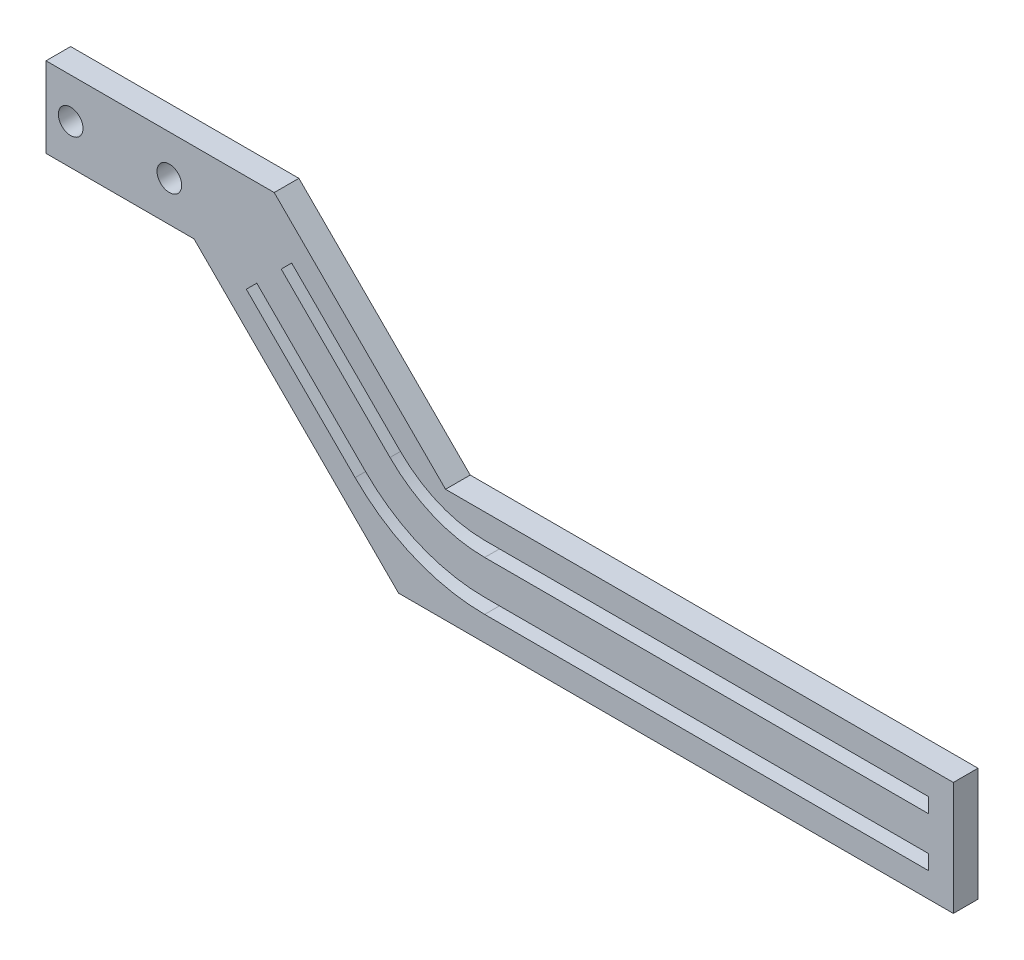
from build123d import *

# Parameters (mm, degrees)
SKETCH2_R           = 2.5
BOSS_EXTRUDE1_DEPTH = 5


with BuildPart() as part:
    # Sketch2 → Boss-Extrude1 (new body)
    with BuildSketch(Plane.XY):
        Polygon((-31.414213562, 42.727922061), (3.313708499, 8), (106.242640687, 8), (106.242640687, -15), (-6.213203436, -15), (-47.67766953, 26.464466094), (-77.67766953, 26.464466094), (-77.67766953, 42.727922061), align=None)
        with Locations((-72.67766953, 34.596194078)):
            Circle(SKETCH2_R, mode=Mode.SUBTRACT)
        with Locations((-52.67766953, 34.596194078)):
            Circle(SKETCH2_R, mode=Mode.SUBTRACT)
        with BuildLine():
            Line((-27.878679656, 32.121320344), (-5.828427125, 10.071067812))
            ThreePointArc((-5.828427125, 10.071067812), (2.003845362, 4.83771065), (11.242640687, 3))
            Line((11.242640687, 3), (101.242640687, 3))
            Line((101.242640687, 3), (101.242640687, 0))
            Line((101.242640687, 0), (11.242640687, 0))
            ThreePointArc((11.242640687, 0), (0.855795065, 2.066072052), (-7.949747468, 7.949747468))
            Line((-7.949747468, 7.949747468), (-30, 30))
            Line((-30, 30), (-27.878679656, 32.121320344))
        make_face(mode=Mode.SUBTRACT)
        with BuildLine():
            Line((-34.949747468, 25.050252532), (-12.899494937, 3))
            ThreePointArc((-12.899494937, 3), (-1.822988962, -4.401084675), (11.242640687, -7))
            Line((11.242640687, -7), (101.242640687, -7))
            Line((101.242640687, -7), (101.242640687, -10))
            Line((101.242640687, -10), (11.242640687, -10))
            ThreePointArc((11.242640687, -10), (-2.971039259, -7.172723273), (-15.02081528, 0.878679656))
            Line((-15.02081528, 0.878679656), (-37.071067812, 22.928932188))
            Line((-37.071067812, 22.928932188), (-34.949747468, 25.050252532))
        make_face(mode=Mode.SUBTRACT)
    extrude(amount=BOSS_EXTRUDE1_DEPTH)


solid = part.part
